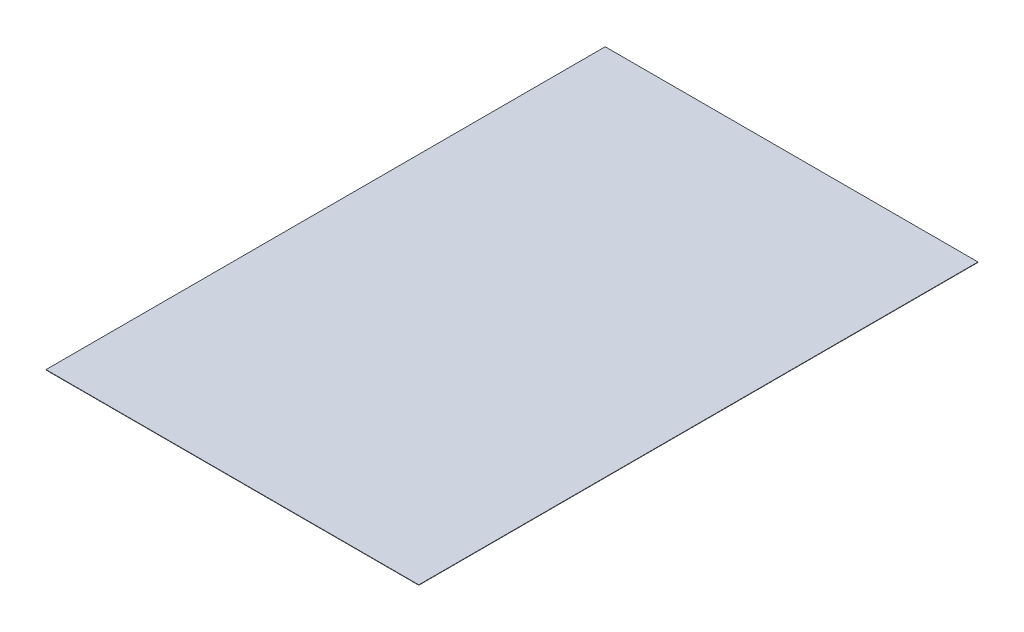
from build123d import *

# Parameters (mm, degrees)
SKETCH1_W           = 6096
SKETCH1_H           = 9144
BOSS_EXTRUDE1_DEPTH = 6


with BuildPart() as part:
    # Sketch1 → Boss-Extrude1 (new body)
    with BuildSketch(Plane(origin=(0, 0, 0), x_dir=(1, 0, 0), z_dir=(0, 1, 0))):
        Rectangle(SKETCH1_W, SKETCH1_H)
    extrude(amount=BOSS_EXTRUDE1_DEPTH)


solid = part.part
